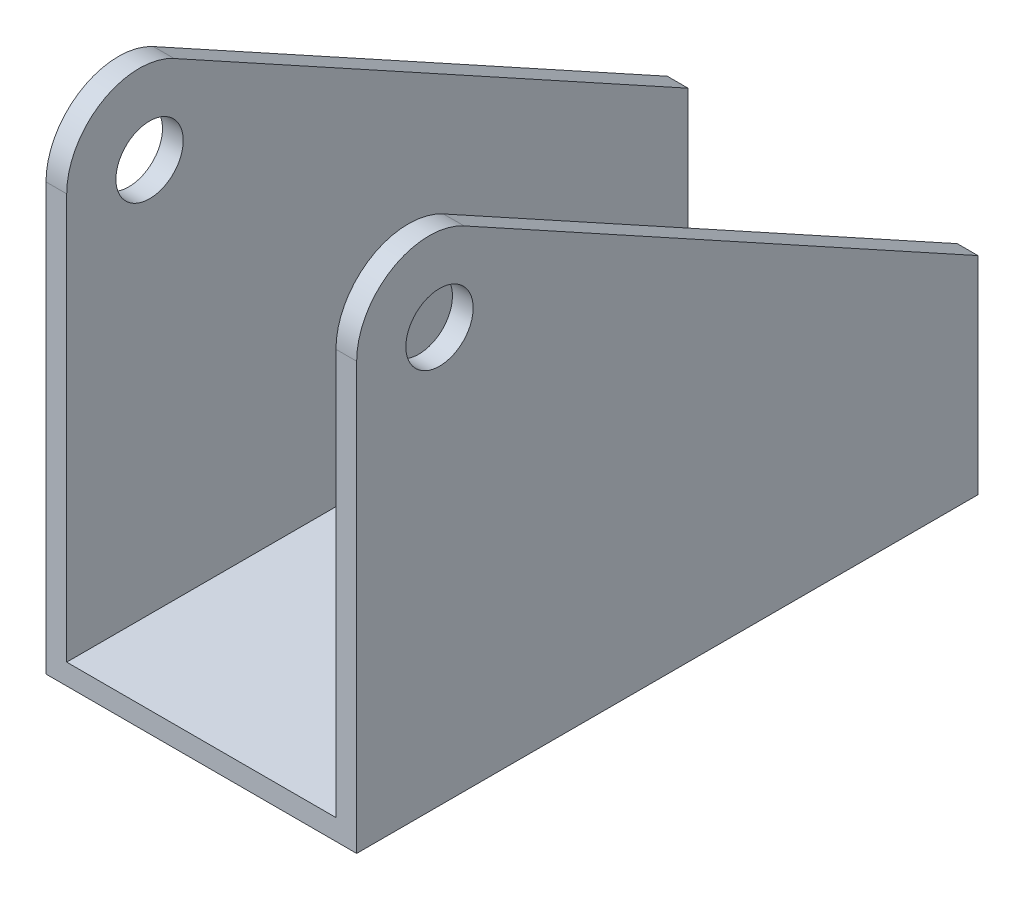
from build123d import *

# Parameters (mm, degrees)
EXTRUDE_1_DEPTH     = 60
SKETCH_2_R          = 3.25
CUT_EXTRUDE_1_DEPTH = 31
FILLET_1_R          = 7
SKETCH_3_R          = 3.25
CUT_EXTRUDE_2_DEPTH = 3


with BuildPart() as part:
    # 草图1 → 凸台-拉伸1 (new body)
    with BuildSketch(Plane.XY):
        Polygon((-13, -20.797836643), (-13, -73.797836643), (13, -73.797836643), (13, -20.797836643), (15, -20.797836643), (15, -75.797836643), (-15, -75.797836643), (-15, -20.797836643), align=None)
    extrude(amount=EXTRUDE_1_DEPTH)

    # 草图2 → 切除-拉伸1 (cut, through all)
    with BuildSketch(Plane(origin=(15, 0, 0), x_dir=(0, 0, -1), z_dir=(1, 0, 0))):
        with Locations((-52, -35.797836643)):
            Circle(SKETCH_2_R)
        Polygon((-60, -20.797836643), (-60, -22.797836643), (0, -55.797836643), (0, -20.797836643), align=None)
    extrude(amount=-CUT_EXTRUDE_1_DEPTH, mode=Mode.SUBTRACT)

    # 圆角1
    fillet_1_edges = [part.edges().sort_by_distance(p)[0] for p in [
        (14, -22.797836643, 60),
        (-14, -22.797836643, 60),
    ]]
    fillet(fillet_1_edges, radius=FILLET_1_R)

    # 草图3 → 切除-拉伸2 (cut, through all)
    with BuildSketch(Plane(origin=(0, -73.797836643, 0), x_dir=(1, 0, 0), z_dir=(0, 1, 0))):
        with Locations((0, -12)):
            Circle(SKETCH_3_R)
    extrude(amount=-CUT_EXTRUDE_2_DEPTH, mode=Mode.SUBTRACT)


solid = part.part
